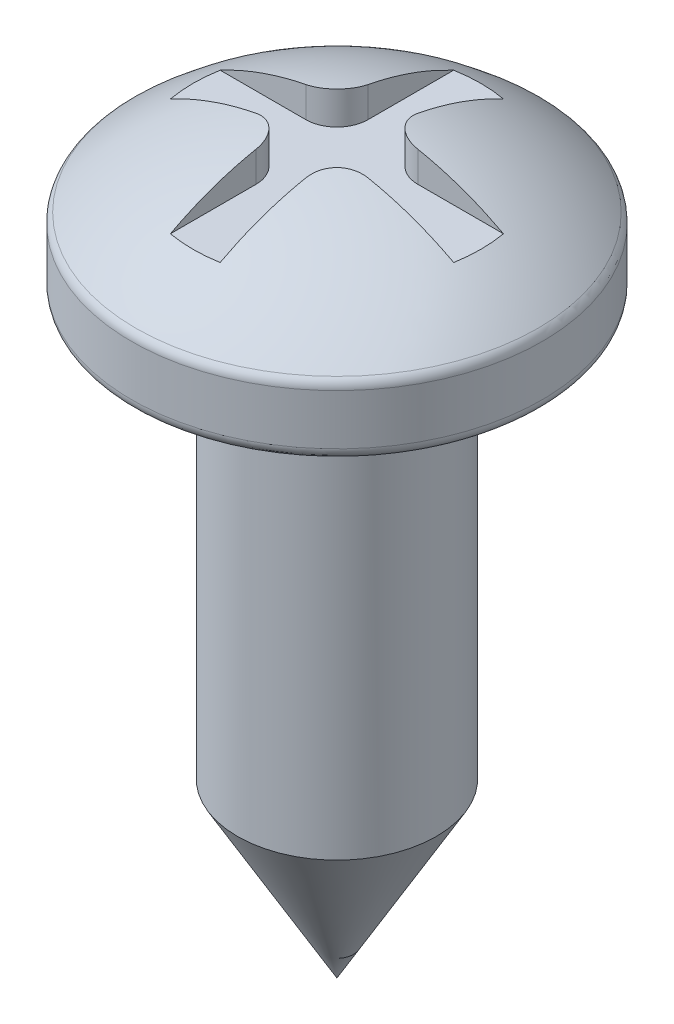
from build123d import *

# Parameters (mm, degrees)
CORTAR_EXTRUIR1_START = -1.8
CORTAR_EXTRUIR1_DEPTH = 3


with BuildPart() as part:
    # Croquis1 → Revolución1 (revolve)
    with BuildSketch(Plane.XY):
        with BuildLine():
            Line((0, 0), (0, 11.9))
            ThreePointArc((0, 11.9), (1.726548348, 11.569000929), (3.231811568, 10.660864252))
            ThreePointArc((3.231811568, 10.660864252), (3.282156956, 10.593022088), (3.3, 10.5104458))
            Line((3.3, 10.5104458), (3.3, 9.7))
            ThreePointArc((3.3, 9.7), (3.241421356, 9.558578644), (3.1, 9.5))
            Line((3.1, 9.5), (1.6, 9.5))
            Line((1.6, 9.5), (1.6, 2.771281292))
            Line((1.6, 2.771281292), (0, 0))
        make_face()
    revolve(axis=Axis((0, 0, 0), (0, 1, 0)))

    # Croquis2 → Cortar-Extruir1 (cut)
    with BuildSketch(Plane.XZ.offset(-9.5).offset(CORTAR_EXTRUIR1_START)):
        with BuildLine():
            Line((-0.4, 3.2), (-0.4, 0.9))
            ThreePointArc((-0.4, 0.9), (-0.546446609, 0.546446609), (-0.9, 0.4))
            Line((-0.9, 0.4), (-3.2, 0.4))
            Line((-3.2, 0.4), (-3.2, -0.4))
            Line((-3.2, -0.4), (-0.9, -0.4))
            ThreePointArc((-0.9, -0.4), (-0.546446609, -0.546446609), (-0.4, -0.9))
            Line((-0.4, -0.9), (-0.4, -3.2))
            Line((-0.4, -3.2), (0.4, -3.2))
            Line((0.4, -3.2), (0.4, -0.9))
            ThreePointArc((0.4, -0.9), (0.546446609, -0.546446609), (0.9, -0.4))
            Line((0.9, -0.4), (3.2, -0.4))
            Line((3.2, -0.4), (3.2, 0.4))
            Line((3.2, 0.4), (0.9, 0.4))
            ThreePointArc((0.9, 0.4), (0.546446609, 0.546446609), (0.4, 0.9))
            Line((0.4, 0.9), (0.4, 3.2))
            Line((0.4, 3.2), (-0.4, 3.2))
        make_face()
    extrude(amount=-CORTAR_EXTRUIR1_DEPTH, mode=Mode.SUBTRACT)


solid = part.part
